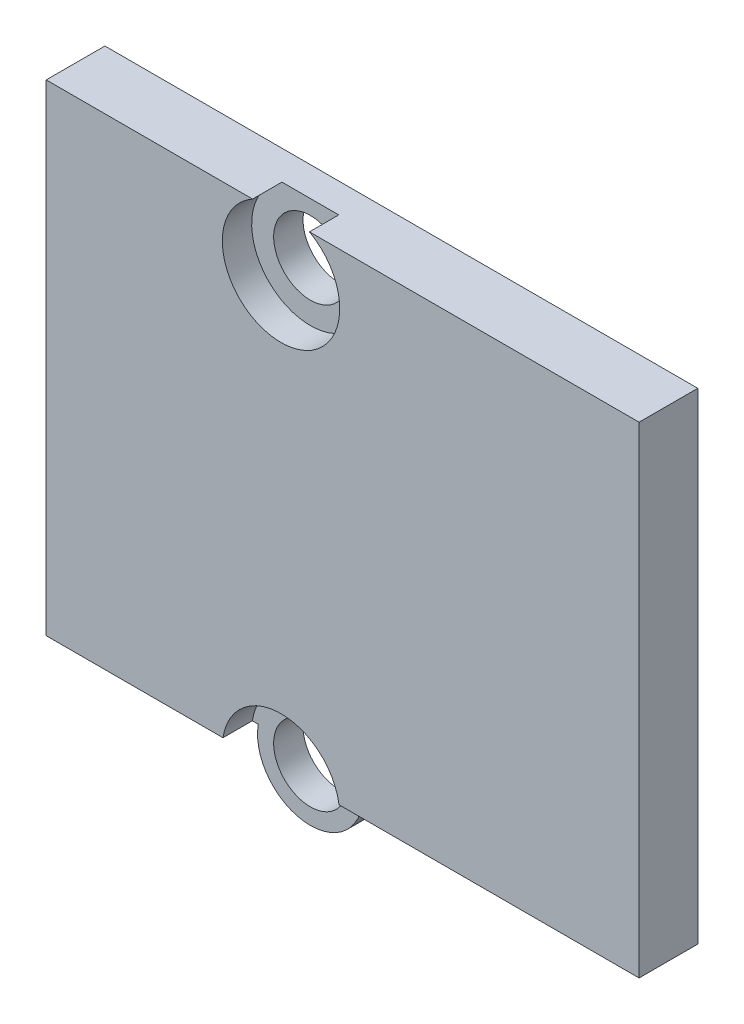
from build123d import *

# Parameters (mm, degrees)
ESBO_O1_R                = 1.25
RESSALTO_EXTRUS_O1_DEPTH = 2
ESBO_O2_R                = 2
CORTE_EXTRUS_O1_DEPTH    = 1


with BuildPart() as part:
    # Esboço1 → Ressalto-extrusão1 (new body)
    with BuildSketch(Plane.XY):
        with BuildLine():
            Line((12.2, 16.7), (-8, 16.7))
            Line((-8, 16.7), (-8, 0.3))
            Line((-8, 0.3), (-1.774823935, 0.3))
            ThreePointArc((-1.774823935, 0.3), (0, -1.8), (1.774823935, 0.3))
            Line((1.774823935, 0.3), (12.2, 0.3))
            Line((12.2, 0.3), (12.2, 16.7))
        make_face()
        Circle(ESBO_O1_R, mode=Mode.SUBTRACT)
        with Locations((0, 14.95)):
            Circle(ESBO_O1_R, mode=Mode.SUBTRACT)
    extrude(amount=RESSALTO_EXTRUS_O1_DEPTH)

    # Esboço2 → Corte-extrusão1 (cut)
    with BuildSketch(Plane.XY.offset(2)):
        with Locations((0, 14.95)):
            Circle(ESBO_O2_R)
        Circle(ESBO_O2_R)
    extrude(amount=-CORTE_EXTRUS_O1_DEPTH, mode=Mode.SUBTRACT)


solid = part.part
